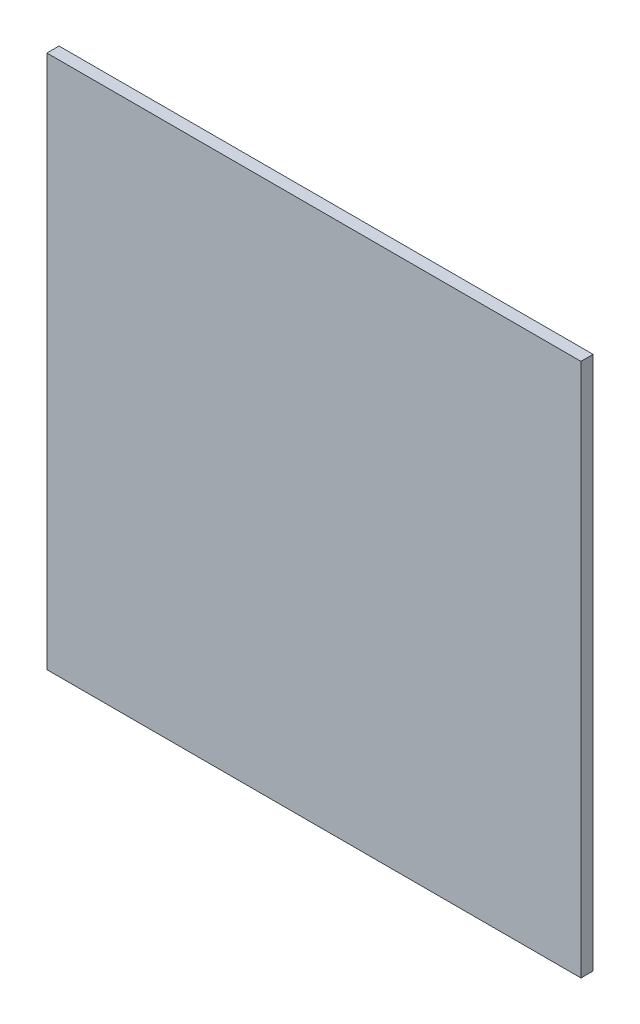
from build123d import *

# Parameters (mm, degrees)
SKETCH1_W           = 139.7
SKETCH1_H           = 139.7
BOSS_EXTRUDE1_DEPTH = 3.175


with BuildPart() as part:
    # Sketch1 → Boss-Extrude1 (new body)
    with BuildSketch(Plane.XY):
        with Locations((1.5875, 73.025)):
            Rectangle(SKETCH1_W, SKETCH1_H)
    extrude(amount=BOSS_EXTRUDE1_DEPTH)


solid = part.part
